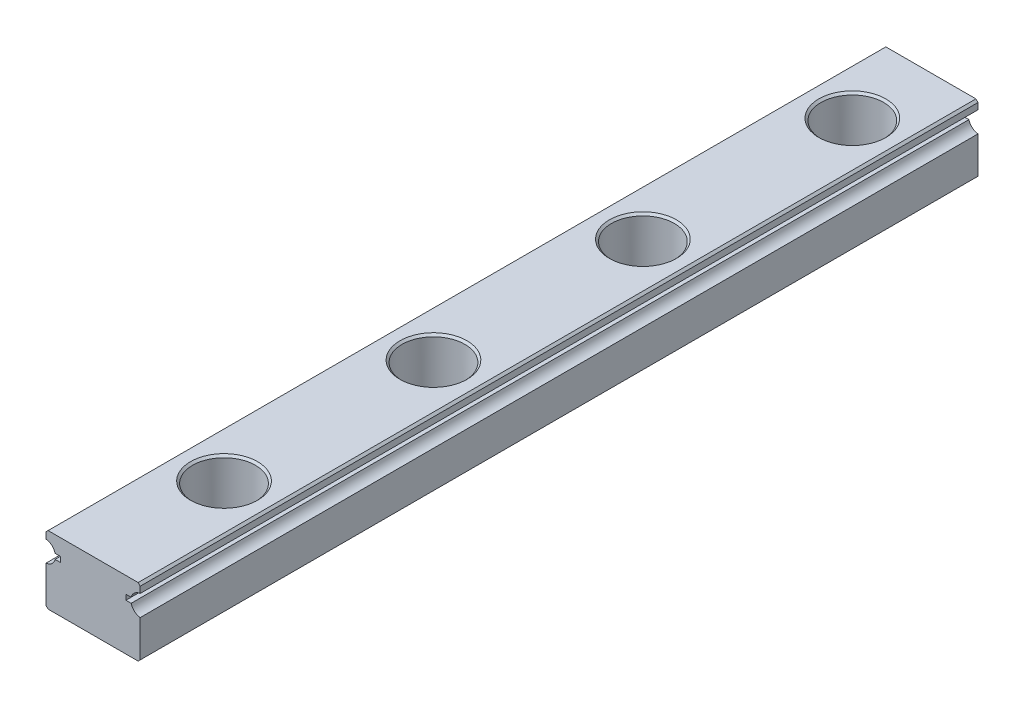
from build123d import *

# Parameters (mm, degrees)
EXTRUDE1_DEPTH                     = 80
HOLE_WIZARD_M3_1_D                 = 3.5
HOLE_WIZARD_M3_1_CBORE_D           = 6
HOLE_WIZARD_M3_1_CBORE_DEPTH       = 4.5
CHAMFER_1_SIZE                     = 0.2
PATTERN_LINEAR_1_COUNT             = 4
PATTERN_LINEAR_1_PITCH             = 20
CHAMFER_1_OF_PATTERN_LINEAR_1_SIZE = 0.2


with BuildPart() as part:
    # Sketch1 → Extrude1 (new body)
    with BuildSketch(Plane.XY):
        with BuildLine():
            Line((-4.3, -3.25), (4.3, -3.25))
            Line((4.3, -3.25), (4.5, -3.05))
            Line((4.5, -3.05), (4.5, 0.455012563))
            ThreePointArc((4.5, 0.455012563), (3.948817336, 0.691078965), (3.631754163, 1.2))
            Line((3.631754163, 1.2), (3.131754163, 1.2))
            Line((3.131754163, 1.2), (3.131754163, 1.7))
            Line((3.131754163, 1.7), (3.631754163, 1.7))
            ThreePointArc((3.631754163, 1.7), (3.948817336, 2.208921035), (4.5, 2.444987437))
            Line((4.5, 2.444987437), (4.5, 3.05))
            Line((4.5, 3.05), (4.3, 3.25))
            Line((4.3, 3.25), (-4.3, 3.25))
            Line((-4.3, 3.25), (-4.5, 3.05))
            Line((-4.5, 3.05), (-4.5, 2.444987437))
            ThreePointArc((-4.5, 2.444987437), (-3.948817336, 2.208921035), (-3.631754163, 1.7))
            Line((-3.631754163, 1.7), (-3.131754163, 1.7))
            Line((-3.131754163, 1.7), (-3.131754163, 1.2))
            Line((-3.131754163, 1.2), (-3.631754163, 1.2))
            ThreePointArc((-3.631754163, 1.2), (-3.948817336, 0.691078965), (-4.5, 0.455012563))
            Line((-4.5, 0.455012563), (-4.5, -3.05))
            Line((-4.5, -3.05), (-4.3, -3.25))
        make_face()
    extrude(amount=EXTRUDE1_DEPTH)

    # M3 平盤頭機械螺釘的柱孔1 (through all)
    with Locations(Plane(origin=(0, 3.25, 0), x_dir=(1, 0, 0), z_dir=(0, 1, 0))):
        with Locations((0, -7.5)):
            hole_wizard_m3_1 = CounterBoreHole(HOLE_WIZARD_M3_1_D / 2, HOLE_WIZARD_M3_1_CBORE_D / 2, HOLE_WIZARD_M3_1_CBORE_DEPTH)

    # 導角1
    chamfer_1_edges = [part.edges().sort_by_distance(p)[0] for p in [
        (-3, 3.25, 7.5),
        (1.75, -3.25, 7.5),
    ]]
    chamfer(chamfer_1_edges, length=CHAMFER_1_SIZE)

    # 直線複製排列1: M3 平盤頭機械螺釘的柱孔1 ×4
    with Locations(*[(0, 0, i * PATTERN_LINEAR_1_PITCH) for i in range(1, PATTERN_LINEAR_1_COUNT)]):
        add(hole_wizard_m3_1, mode=Mode.SUBTRACT)

    # 導角1 of 直線複製排列1
    chamfer_1_of_pattern_linear_1_edges = [part.edges().sort_by_distance(p)[0] for p in [
        (-3, 3.25, 27.5),
        (1.75, -3.25, 27.5),
        (-3, 3.25, 47.5),
        (1.75, -3.25, 47.5),
        (-3, 3.25, 67.5),
        (1.75, -3.25, 67.5),
    ]]
    chamfer(chamfer_1_of_pattern_linear_1_edges, length=CHAMFER_1_OF_PATTERN_LINEAR_1_SIZE)


solid = part.part
